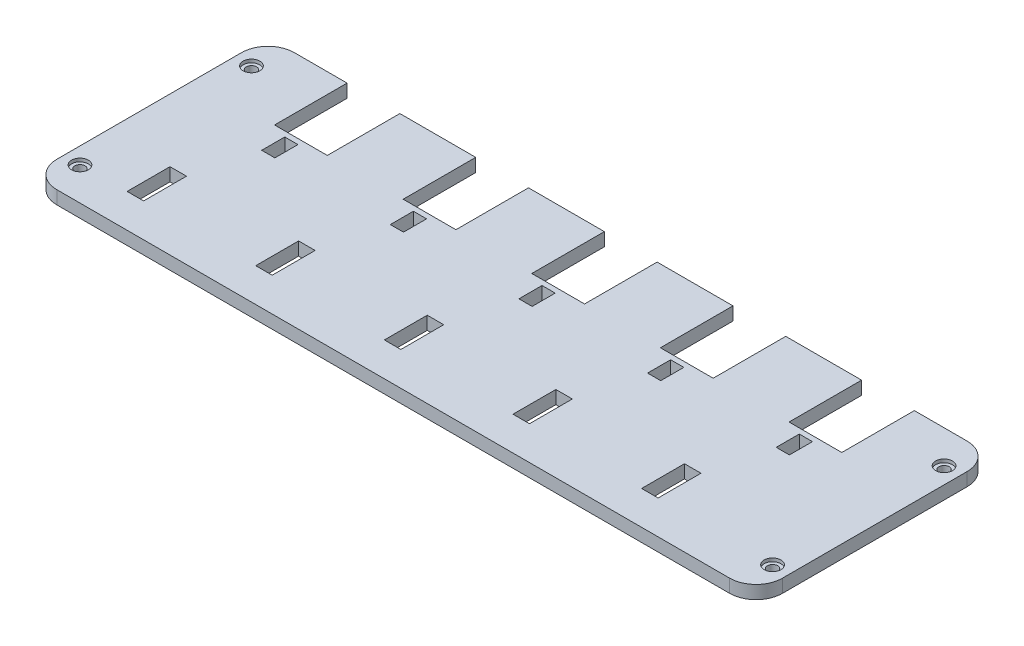
from build123d import *

# Parameters (mm, degrees)
SKETCH1_R           = 0.775
SKETCH1_W           = 2
SKETCH1_H           = 3.5
SKETCH1_W_2         = 2.5
SKETCH1_H_2         = 6.5
BOSS_EXTRUDE1_DEPTH = 2
SKETCH2_R           = 1.275
CUT_EXTRUDE1_DEPTH  = 0.5
SKETCH3_W           = 8
SKETCH3_H           = 11
CUT_EXTRUDE2_DEPTH  = 3


with BuildPart() as part:
    # Sketch1 → Boss-Extrude1 (new body)
    with BuildSketch(Plane(origin=(0, 0, 0), x_dir=(1, 0, 0), z_dir=(0, 1, 0))):
        with BuildLine():
            Line((-0.26263299, 9.170981105), (-0.26263299, -1.829018895))
            Line((-0.26263299, -1.829018895), (-7.76263299, -1.829018895))
            Line((-7.76263299, -1.829018895), (-7.76263299, 9.170981105))
            Line((-7.76263299, 9.170981105), (-19.76263299, 9.170981105))
            Line((-19.76263299, 9.170981105), (-19.76263299, -1.829018895))
            Line((-19.76263299, -1.829018895), (-27.26263299, -1.829018895))
            Line((-27.26263299, -1.829018895), (-27.26263299, 9.170981105))
            Line((-27.26263299, 9.170981105), (-34.51263299, 9.170981105))
            Line((-34.51263299, 9.170981105), (-35.51263299, 9.170981105))
            ThreePointArc((-35.51263299, 9.170981105), (-38.341060114, 7.99940823), (-39.51263299, 5.170981105))
            Line((-39.51263299, 5.170981105), (-39.51263299, -22.829018895))
            ThreePointArc((-39.51263299, -22.829018895), (-38.341060114, -25.65744602), (-35.51263299, -26.829018895))
            Line((-35.51263299, -26.829018895), (-34.51263299, -26.829018895))
            Line((-34.51263299, -26.829018895), (65.48736701, -26.829018895))
            Line((65.48736701, -26.829018895), (66.48736701, -26.829018895))
            ThreePointArc((66.48736701, -26.829018895), (69.315794135, -25.65744602), (70.48736701, -22.829018895))
            Line((70.48736701, -22.829018895), (70.48736701, 5.170981105))
            ThreePointArc((70.48736701, 5.170981105), (69.315794135, 7.99940823), (66.48736701, 9.170981105))
            Line((66.48736701, 9.170981105), (65.48736701, 9.170981105))
            Line((65.48736701, 9.170981105), (58.23736701, 9.170981105))
            Line((58.23736701, 9.170981105), (58.23736701, -1.829018895))
            Line((58.23736701, -1.829018895), (50.73736701, -1.829018895))
            Line((50.73736701, -1.829018895), (50.73736701, 9.170981105))
            Line((50.73736701, 9.170981105), (38.73736701, 9.170981105))
            Line((38.73736701, 9.170981105), (38.73736701, -1.829018895))
            Line((38.73736701, -1.829018895), (31.23736701, -1.829018895))
            Line((31.23736701, -1.829018895), (31.23736701, 9.170981105))
            Line((31.23736701, 9.170981105), (19.23736701, 9.170981105))
            Line((19.23736701, 9.170981105), (19.23736701, -1.829018895))
            Line((19.23736701, -1.829018895), (11.73736701, -1.829018895))
            Line((11.73736701, -1.829018895), (11.73736701, 9.170981105))
            Line((11.73736701, 9.170981105), (-0.26263299, 9.170981105))
        make_face()
        with Locations((-37.01263299, 4.170981105)):
            Circle(SKETCH1_R, mode=Mode.SUBTRACT)
        with Locations((-37.01263299, -21.829018895)):
            Circle(SKETCH1_R, mode=Mode.SUBTRACT)
        with Locations((67.98736701, 4.170981105)):
            Circle(SKETCH1_R, mode=Mode.SUBTRACT)
        with Locations((67.98736701, -21.829018895)):
            Circle(SKETCH1_R, mode=Mode.SUBTRACT)
        with Locations((-24.16263299, -4.379018895)):
            Rectangle(SKETCH1_W, SKETCH1_H, mode=Mode.SUBTRACT)
        with Locations((-4.66263299, -4.379018895)):
            Rectangle(SKETCH1_W, SKETCH1_H, mode=Mode.SUBTRACT)
        with Locations((14.83736701, -4.379018895)):
            Rectangle(SKETCH1_W, SKETCH1_H, mode=Mode.SUBTRACT)
        with Locations((34.33736701, -4.379018895)):
            Rectangle(SKETCH1_W, SKETCH1_H, mode=Mode.SUBTRACT)
        with Locations((53.83736701, -4.379018895)):
            Rectangle(SKETCH1_W, SKETCH1_H, mode=Mode.SUBTRACT)
        with Locations((-9.21263299, -18.479018895)):
            Rectangle(SKETCH1_W_2, SKETCH1_H_2, mode=Mode.SUBTRACT)
        with Locations((-28.71263299, -18.479018895)):
            Rectangle(SKETCH1_W_2, SKETCH1_H_2, mode=Mode.SUBTRACT)
        with Locations((10.28736701, -18.479018895)):
            Rectangle(SKETCH1_W_2, SKETCH1_H_2, mode=Mode.SUBTRACT)
        with Locations((29.78736701, -18.479018895)):
            Rectangle(SKETCH1_W_2, SKETCH1_H_2, mode=Mode.SUBTRACT)
        with Locations((49.28736701, -18.479018895)):
            Rectangle(SKETCH1_W_2, SKETCH1_H_2, mode=Mode.SUBTRACT)
    extrude(amount=BOSS_EXTRUDE1_DEPTH)

    # Sketch2 → Cut-Extrude1 (cut)
    with BuildSketch(Plane(origin=(0, 2, 0), x_dir=(1, 0, 0), z_dir=(0, 1, 0))):
        with Locations((-37.01263299, 4.170981105)):
            Circle(SKETCH2_R)
        with Locations((-37.01263299, -21.829018895)):
            Circle(SKETCH2_R)
        with Locations((67.98736701, 4.170981105)):
            Circle(SKETCH2_R)
        with Locations((67.98736701, -21.829018895)):
            Circle(SKETCH2_R)
    extrude(amount=-CUT_EXTRUDE1_DEPTH, mode=Mode.SUBTRACT)

    # Sketch3 → Cut-Extrude2 (cut, through all)
    with BuildSketch(Plane(origin=(0, 2, 0), x_dir=(1, 0, 0), z_dir=(0, 1, 0))):
        with Locations((-23.51263299, 3.670981105)):
            Rectangle(SKETCH3_W, SKETCH3_H)
        with Locations((-4.01263299, 3.670981105)):
            Rectangle(SKETCH3_W, SKETCH3_H)
        with Locations((15.48736701, 3.670981105)):
            Rectangle(SKETCH3_W, SKETCH3_H)
        with Locations((34.98736701, 3.670981105)):
            Rectangle(SKETCH3_W, SKETCH3_H)
        with Locations((54.48736701, 3.670981105)):
            Rectangle(SKETCH3_W, SKETCH3_H)
    extrude(amount=-CUT_EXTRUDE2_DEPTH, mode=Mode.SUBTRACT)


solid = part.part
